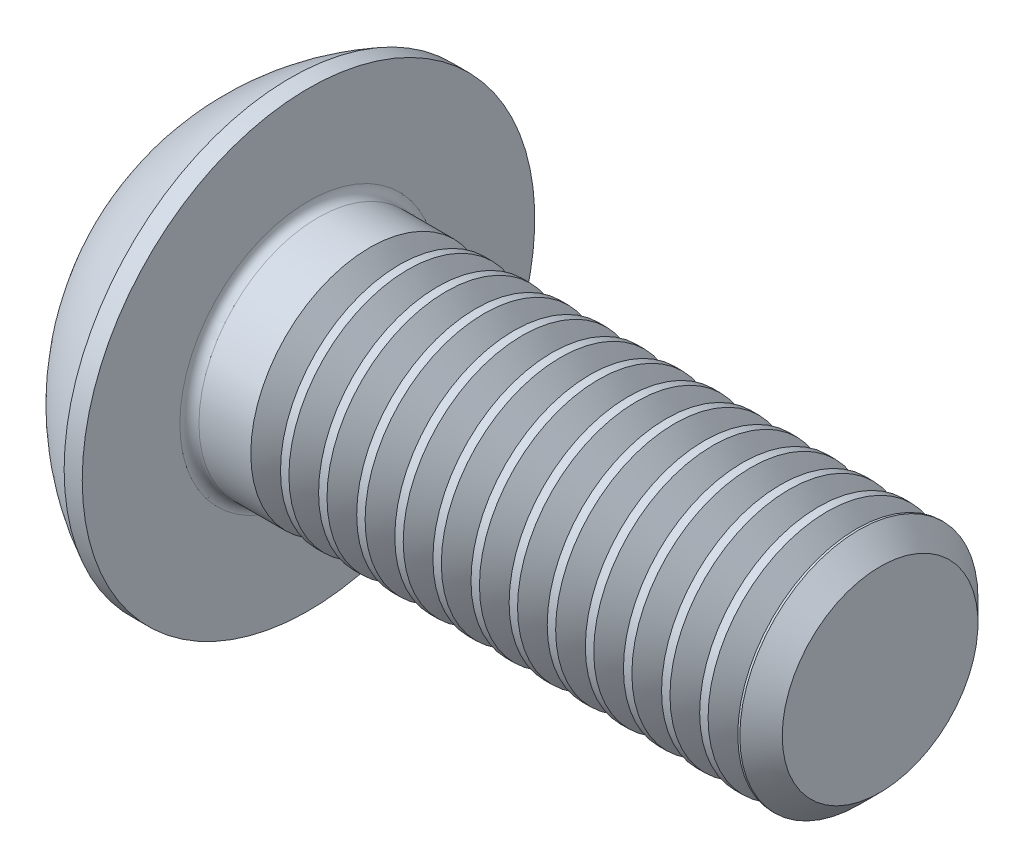
from build123d import *

# Parameters (mm, degrees)
FILLET1_R       = 0.2
HEX_2_DEPTH     = 1.56
THDSCHPAT_COUNT = 14
THDSCHPAT_PITCH = 0.8


with BuildPart() as part:
    # BodySke → BaseBody (revolve)
    with BuildSketch(Plane.XY):
        with BuildLine():
            Line((14.75, 0), (14.75, 2.055))
            Line((14.75, 2.055), (14.305, 2.5))
            Line((14.305, 2.5), (2.75, 2.5))
            Line((2.75, 2.5), (2.75, 4.75))
            Line((2.75, 4.75), (2.37, 4.75))
            ThreePointArc((2.37, 4.75), (0.992680215, 3.754414901), (0, 2.375))
            Line((0, 2.375), (0, 0))
            Line((0, 0), (14.75, 0))
        make_face()
    revolve(axis=Axis((0, 0, 0), (1, 0, 0)))

    # Fillet1
    fillet1_edges = [part.edges().sort_by_distance(p)[0] for p in [
        (2.75, -2.5, 0),
    ]]
    fillet(fillet1_edges, radius=FILLET1_R)

    # Sketch2 → PreBroach (revolve, cut)
    with BuildSketch(Plane.XY):
        Polygon((0, 1.5), (1.56, 1.5), (2.426025404, 0), (0, 0), align=None)
    revolve(axis=Axis((0, 0, 0), (1, 0, 0)), mode=Mode.SUBTRACT)

    # Sketch3 → Hex 2 (cut)
    with BuildSketch(Plane(origin=(0, 0, 0), x_dir=(0, 0, -1), z_dir=(1, 0, 0))):
        Polygon((-1.5, -0.866025404), (-1.5, 0.866025404), (0, 1.732050808), (1.5, 0.866025404), (1.5, -0.866025404), (0, -1.732050808), align=None)
    extrude(amount=HEX_2_DEPTH, mode=Mode.SUBTRACT)

    # ThdSchSke → ThreadSchematic (revolve, cut)
    with BuildSketch(Plane.XY):
        Polygon((4.35, -2.055), (4.038407645, -2.5), (4.038407645, -3.125), (4.661592355, -3.125), (4.661592355, -2.5), align=None)
    threadschematic = revolve(axis=Axis((-3.175, 0, 0), (1, 0, 0)), mode=Mode.SUBTRACT)

    # ThdSchPat: ThreadSchematic ×14
    with Locations(*[(i * THDSCHPAT_PITCH, 0, 0) for i in range(1, THDSCHPAT_COUNT)]):
        add(threadschematic, mode=Mode.SUBTRACT)


solid = part.part
